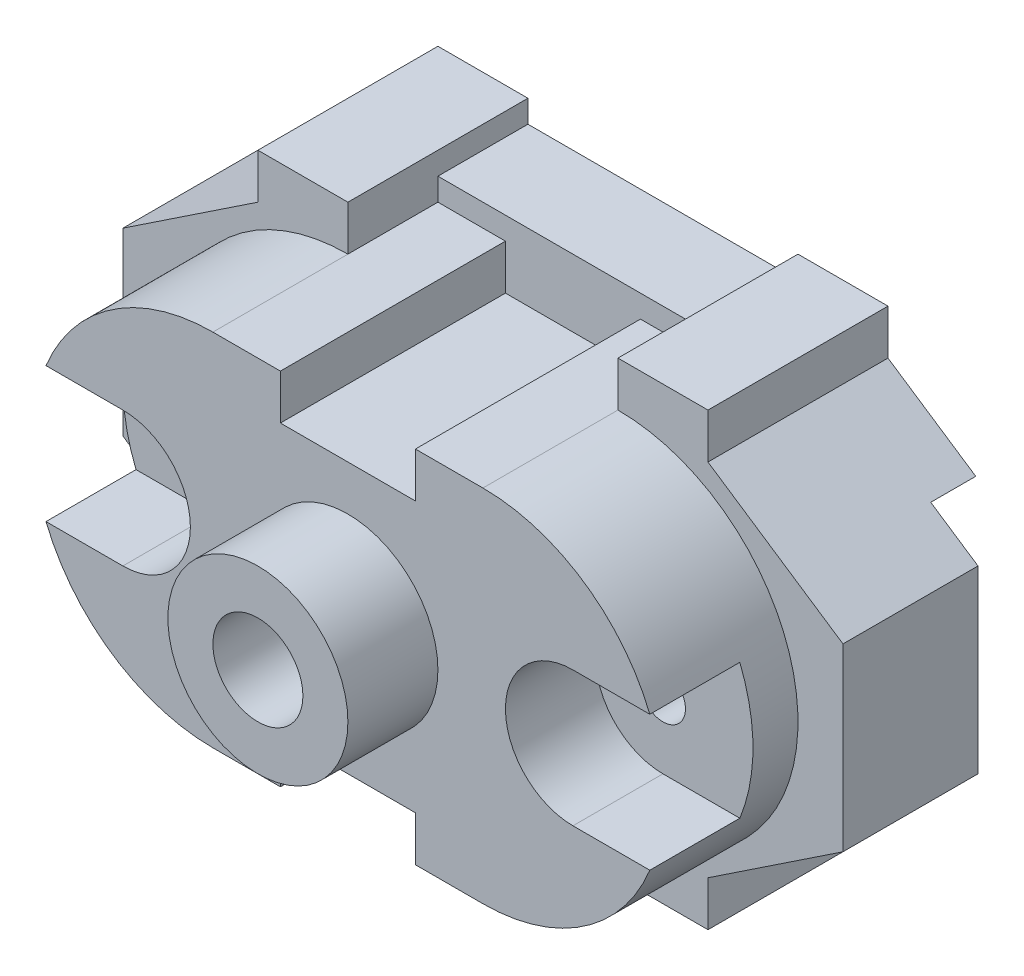
from build123d import *

# Parameters (mm, degrees)
BOSS_EXTRUDE1_DEPTH = 40
BOSS_EXTRUDE2_DEPTH = 30
SKETCH3_R           = 20
BOSS_EXTRUDE3_DEPTH = 20
SKETCH4_R           = 10
CUT_EXTRUDE1_DEPTH  = 185
SKETCH5_R           = 5
CUT_EXTRUDE2_DEPTH  = 185
SKETCH6_R           = 5
CUT_EXTRUDE3_DEPTH  = 20
CUT_EXTRUDE4_DEPTH  = 20
CUT_EXTRUDE5_DEPTH  = 20
CUT_EXTRUDE7_DEPTH  = 10


with BuildPart() as part:
    # Sketch1 → Boss-Extrude1 (new body)
    with BuildSketch(Plane.XY):
        Polygon((0, 40.88699749), (-20, 40.88699749), (-20, 30.88699749), (-50, 10.88699749), (-50, -29.11300251), (-20, -49.11300251), (-20, -59.11300251), (0, -59.11300251), (0, -54.11300251), (60, -54.11300251), (60, -59.11300251), (80, -59.11300251), (80, -49.11300251), (110, -29.11300251), (110, 10.88699749), (80, 30.88699749), (80, 40.88699749), (60, 40.88699749), (60, 35.88699749), (0, 35.88699749), align=None)
    extrude(amount=BOSS_EXTRUDE1_DEPTH)

    # Sketch2 → Boss-Extrude2 (add)
    with BuildSketch(Plane.XY.offset(40)):
        with BuildLine():
            Line((0, 30.88699749), (15, 30.88699749))
            Line((15, 30.88699749), (15, 20.88699749))
            Line((15, 20.88699749), (45, 20.88699749))
            Line((45, 20.88699749), (45, 30.88699749))
            Line((45, 30.88699749), (60, 30.88699749))
            ThreePointArc((60, 30.88699749), (100, -9.11300251), (60, -49.11300251))
            Line((60, -49.11300251), (45, -49.11300251))
            Line((45, -49.11300251), (45, -39.11300251))
            Line((45, -39.11300251), (15, -39.11300251))
            Line((15, -39.11300251), (15, -49.11300251))
            Line((15, -49.11300251), (0, -49.11300251))
            ThreePointArc((0, -49.11300251), (-40, -9.11300251), (0, 30.88699749))
        make_face()
    extrude(amount=BOSS_EXTRUDE2_DEPTH)

    # Sketch3 → Boss-Extrude3 (add)
    with BuildSketch(Plane.XY.offset(70)):
        with Locations((30, -9.11300251)):
            Circle(SKETCH3_R)
    extrude(amount=BOSS_EXTRUDE3_DEPTH)

    # Sketch4 → Cut-Extrude1 (cut)
    with BuildSketch(Plane.XY.offset(90)):
        with Locations((30, -9.11300251)):
            Circle(SKETCH4_R)
    extrude(amount=-CUT_EXTRUDE1_DEPTH, mode=Mode.SUBTRACT)

    # Sketch5 → Cut-Extrude2 (cut)
    with BuildSketch(Plane.XY.offset(70)):
        with Locations((-20, -9.11300251)):
            Circle(SKETCH5_R)
        with Locations((80, -9.11300251)):
            Circle(SKETCH5_R)
    extrude(amount=-CUT_EXTRUDE2_DEPTH, mode=Mode.SUBTRACT)

    # Sketch6 → Cut-Extrude3 (cut)
    with BuildSketch(Plane.XY.offset(70)):
        with BuildLine():
            ThreePointArc((-20, -24.11300251), (-5, -9.11300251), (-20, 5.88699749))
            Line((-20, 5.88699749), (-37.080992435, 5.88699749))
            ThreePointArc((-37.080992435, 5.88699749), (-40, -9.11300251), (-37.080992435, -24.11300251))
            Line((-37.080992435, -24.11300251), (-20, -24.11300251))
        make_face()
        with Locations((-20, -9.11300251)):
            Circle(SKETCH6_R, mode=Mode.SUBTRACT)
        with BuildLine():
            Line((97.080992435, 5.88699749), (80, 5.88699749))
            ThreePointArc((80, 5.88699749), (65, -9.11300251), (80, -24.11300251))
            Line((80, -24.11300251), (97.080992435, -24.11300251))
            ThreePointArc((97.080992435, -24.11300251), (100, -9.11300251), (97.080992435, 5.88699749))
        make_face()
        with Locations((80, -9.11300251)):
            Circle(SKETCH6_R, mode=Mode.SUBTRACT)
    extrude(amount=-CUT_EXTRUDE3_DEPTH, mode=Mode.SUBTRACT)

    # Sketch7 → Cut-Extrude4 (cut)
    with BuildSketch(Plane.XY.offset(40)):
        Polygon((0, 35.88699749), (0, 30.88699749), (15, 30.88699749), (15, 20.88699749), (45, 20.88699749), (45, 30.88699749), (60, 30.88699749), (60, 35.88699749), align=None)
    extrude(amount=-CUT_EXTRUDE4_DEPTH, mode=Mode.SUBTRACT)

    # Sketch8 → Cut-Extrude5 (cut)
    with BuildSketch(Plane.XY.offset(40)):
        Polygon((0, -54.11300251), (0, -49.11300251), (15, -49.11300251), (15, -39.11300251), (45, -39.11300251), (45, -49.11300251), (60, -49.11300251), (60, -54.11300251), align=None)
    extrude(amount=-CUT_EXTRUDE5_DEPTH, mode=Mode.SUBTRACT)

    # Sketch9 → Cut-Extrude7 (cut)
    with BuildSketch(Plane(origin=(0, 0, 0), x_dir=(-1, 0, 0), z_dir=(0, 0, -1))):
        Polygon((-99.5, 17.88699749), (39.5, 17.88699749), (50, 10.88699749), (50, -29.11300251), (39.5, -36.11300251), (-99.5, -36.11300251), (-110, -29.11300251), (-110, 10.88699749), align=None)
    extrude(amount=-CUT_EXTRUDE7_DEPTH, mode=Mode.SUBTRACT)


solid = part.part
